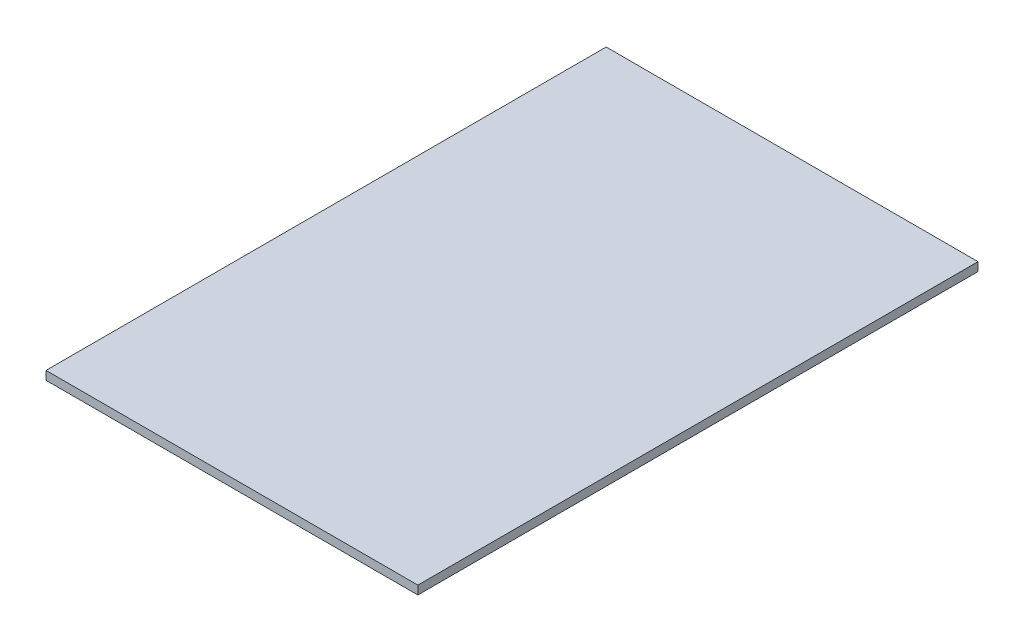
from build123d import *

# Parameters (mm, degrees)
SKETCH1_W           = 736
SKETCH1_H           = 17
BOSS_EXTRUDE1_DEPTH = 1108.7


with BuildPart() as part:
    # Sketch1 → Boss-Extrude1 (new body)
    with BuildSketch(Plane.XY):
        with Locations((63, 8.5)):
            Rectangle(SKETCH1_W, SKETCH1_H)
    extrude(amount=-BOSS_EXTRUDE1_DEPTH)


solid = part.part
